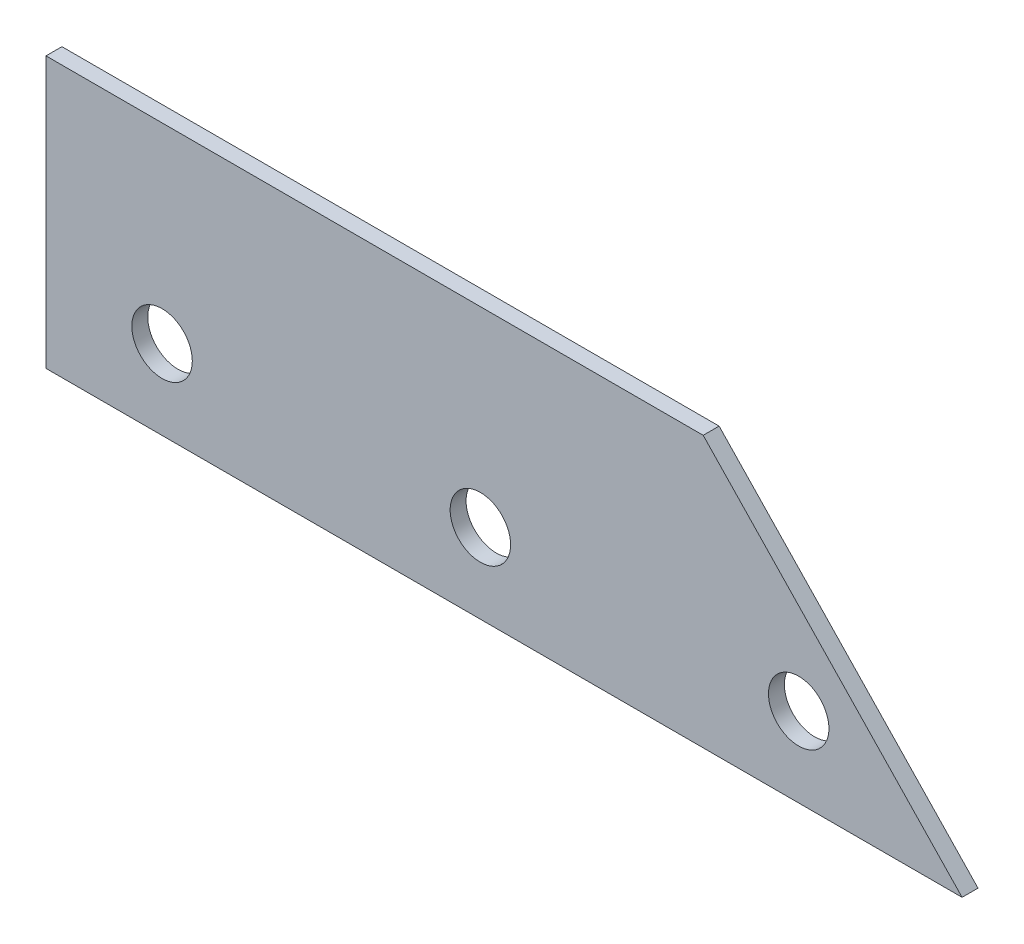
from build123d import *

# Parameters (mm, degrees)
SKETCH_1_R      = 1.9
EXTRUDE_1_DEPTH = 1


with BuildPart() as part:
    # Эскиз1 → Бобышка-Вытянуть1 (new body)
    with BuildSketch(Plane.XY):
        Polygon((45.301358773, 5.375), (102.859703721, 5.375), (86.593533576, 22.383876488), (45.301358773, 22.383876488), align=None)
        with Locations((92.593533576, 10.375)):
            Circle(SKETCH_1_R, mode=Mode.SUBTRACT)
        with Locations((72.593533576, 10.375)):
            Circle(SKETCH_1_R, mode=Mode.SUBTRACT)
        with Locations((52.593533576, 10.375)):
            Circle(SKETCH_1_R, mode=Mode.SUBTRACT)
    extrude(amount=EXTRUDE_1_DEPTH)


solid = part.part
